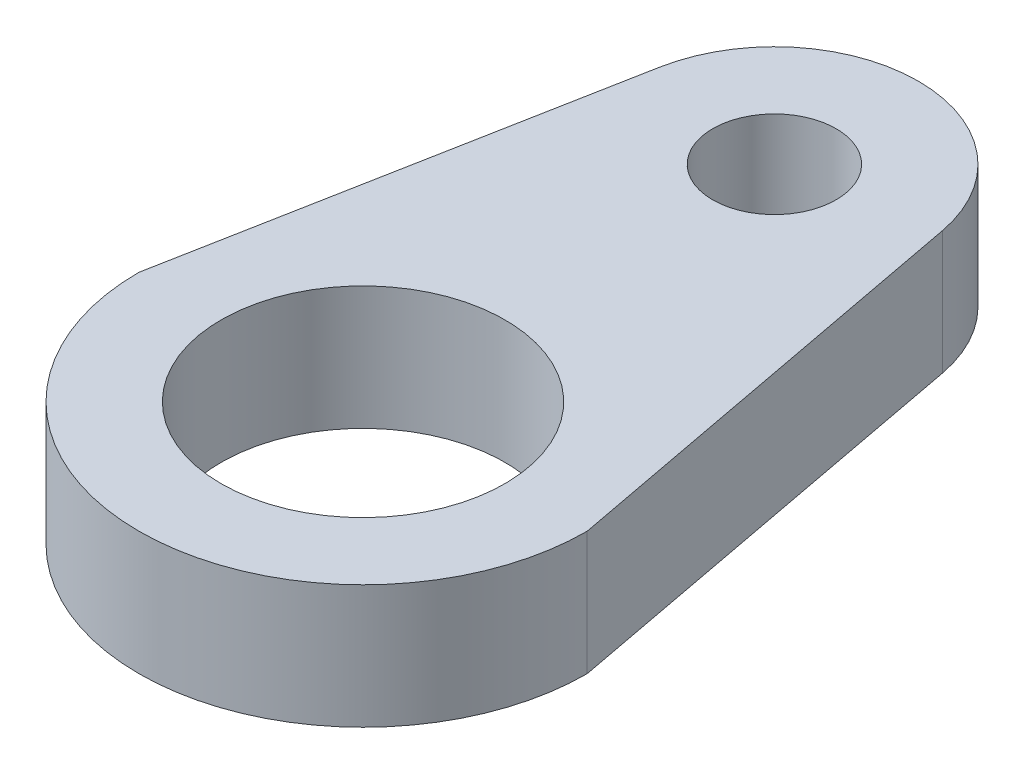
from build123d import *

# Parameters (mm, degrees)
SKETCH1_R           = 3.45
SKETCH1_R_2         = 1.5
BOSS_EXTRUDE1_DEPTH = 1.5


with BuildPart() as part:
    # Sketch1 → Boss-Extrude1 (new body, symmetric)
    with BuildSketch(Plane(origin=(0, 0, 0), x_dir=(1, 0, 0), z_dir=(0, 1, 0))):
        with BuildLine():
            Line((-5.45, 0), (-3.439230286, 10.649380506))
            ThreePointArc((-3.439230286, 10.649380506), (0, 13.5), (3.439230286, 10.649380506))
            Line((3.439230286, 10.649380506), (5.45, 0))
            ThreePointArc((5.45, 0), (0, -5.45), (-5.45, 0))
        make_face()
        Circle(SKETCH1_R, mode=Mode.SUBTRACT)
        with Locations((0, 10)):
            Circle(SKETCH1_R_2, mode=Mode.SUBTRACT)
    extrude(amount=BOSS_EXTRUDE1_DEPTH, both=True)


solid = part.part
